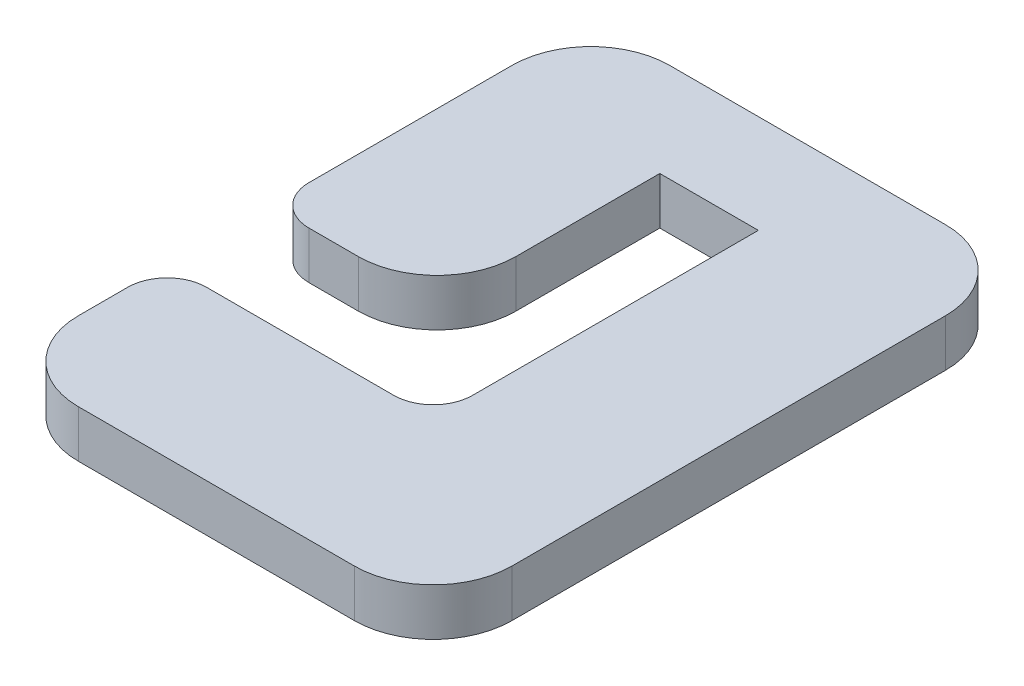
from build123d import *

# Parameters (mm, degrees)
BOSS_EXTRUDE1_DEPTH = 2.4
FILLET1_R           = 4
FILLET2_R           = 4
FILLET3_R           = 2


with BuildPart() as part:
    # Sketch1 → Boss-Extrude1 (new body)
    with BuildSketch(Plane(origin=(0, 0, 0), x_dir=(1, 0, 0), z_dir=(0, 1, 0))):
        Polygon((-11, -15), (11, -15), (11, 15), (-11, 15), (-11, -1.3), (-2.5, -1.3), (-2.5, 10), (2.5, 10), (2.5, -6.5), (-2.5, -6.5), (-11, -6.5), align=None)
    extrude(amount=BOSS_EXTRUDE1_DEPTH)

    # Fillet1
    fillet1_edges = [part.edges().sort_by_distance(p)[0] for p in [
        (-2.5, 1.2, 1.3),
    ]]
    fillet(fillet1_edges, radius=FILLET1_R)

    # Fillet2
    fillet2_edges = [part.edges().sort_by_distance(p)[0] for p in [
        (11, 1.2, 15),
        (-11, 1.2, 15),
        (-11, 1.2, -15),
        (11, 1.2, -15),
    ]]
    fillet(fillet2_edges, radius=FILLET2_R)

    # Fillet3
    fillet3_edges = [part.edges().sort_by_distance(p)[0] for p in [
        (-11, 1.2, 6.5),
        (2.5, 1.2, 6.5),
        (-11, 1.2, 1.3),
    ]]
    fillet(fillet3_edges, radius=FILLET3_R)


solid = part.part
